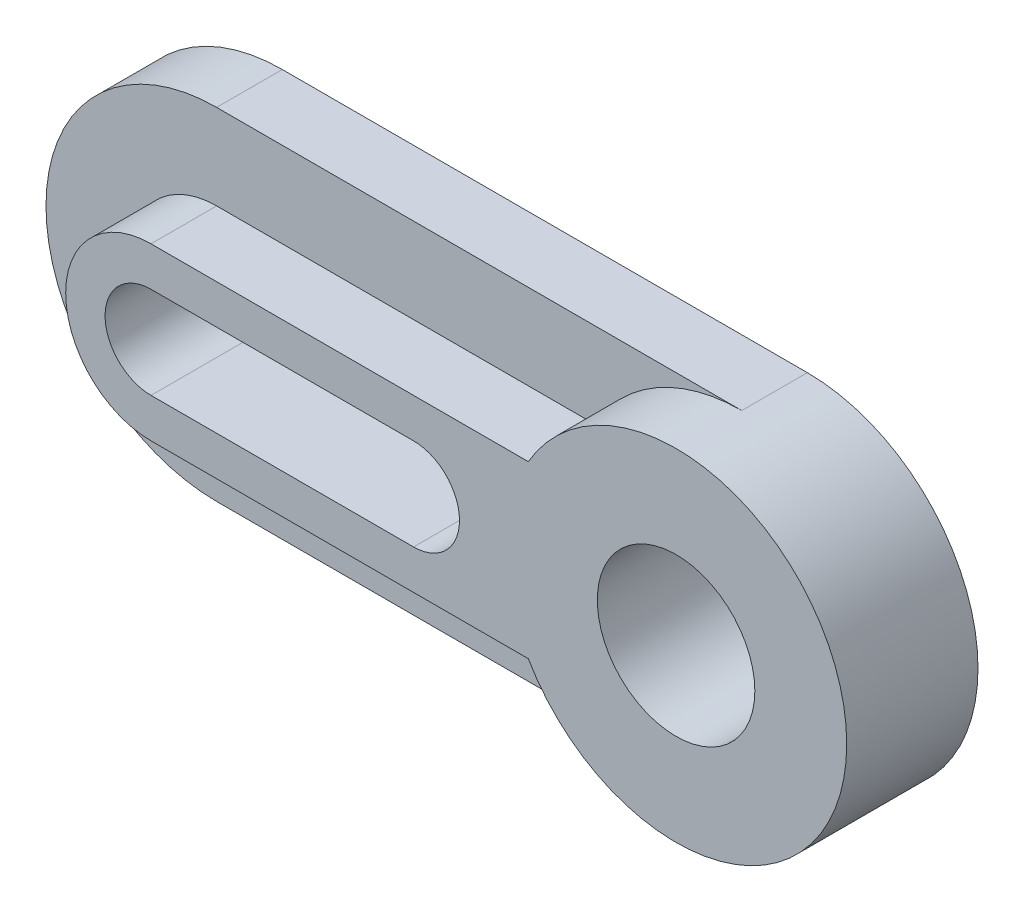
from build123d import *

# Parameters (mm, degrees)
RESSALTO_EXTRUS_O1_DEPTH = 10
RESSALTO_EXTRUS_O2_DEPTH = 10
ESBO_O3_R                = 12
CORTE_EXTRUS_O1_DEPTH    = 21


with BuildPart() as part:
    # Esboço1 → Ressalto-extrusão1 (new body)
    with BuildSketch(Plane.XY):
        with BuildLine():
            Line((0, 26), (80, 26))
            ThreePointArc((80, 26), (106, 0), (80, -26))
            Line((80, -26), (0, -26))
            ThreePointArc((0, -26), (-26, 0), (0, 26))
        make_face()
    extrude(amount=RESSALTO_EXTRUS_O1_DEPTH)

    # Esboço2 → Ressalto-extrusão2 (add)
    with BuildSketch(Plane.XY.offset(10)):
        with BuildLine():
            Line((0, 13), (57.483339502, 13))
            ThreePointArc((57.483339502, 13), (106, 0), (57.483339502, -13))
            Line((57.483339502, -13), (0, -13))
            ThreePointArc((0, -13), (-13, 0), (0, 13))
        make_face()
    extrude(amount=RESSALTO_EXTRUS_O2_DEPTH)

    # Esboço3 → Corte-extrusão1 (cut, through all)
    with BuildSketch(Plane.XY.offset(20)):
        with Locations((80, 0)):
            Circle(ESBO_O3_R)
        with BuildLine():
            Line((0, 7), (40, 7))
            ThreePointArc((40, 7), (47, 0), (40, -7))
            Line((40, -7), (0, -7))
            ThreePointArc((0, -7), (-7, 0), (0, 7))
        make_face()
    extrude(amount=-CORTE_EXTRUS_O1_DEPTH, mode=Mode.SUBTRACT)


solid = part.part
